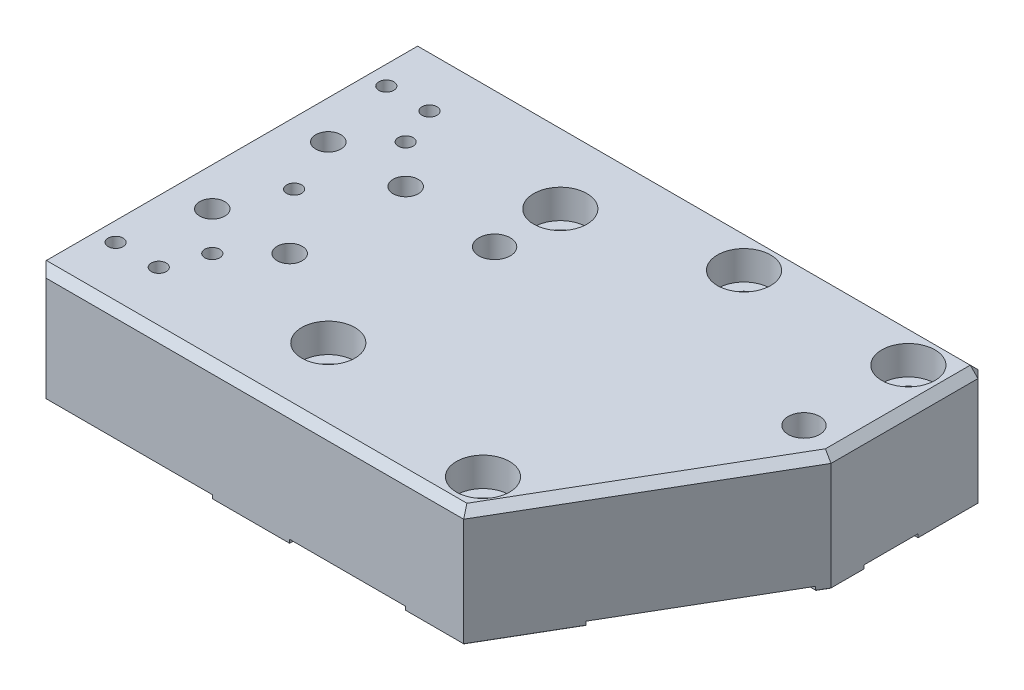
from build123d import *

# Parameters (mm, degrees)
EXTRUDE1_DEPTH                                   = 38.1
SKETCH2_R                                        = 1.59512
PIN_SLOT_HOLES_TO_MAGNET_BLOCK_DEPTH             = 6.35
SKETCH3_W                                        = 19.05
SKETCH3_H                                        = 9.525
SKETCH3_W_2                                      = 7.62
SKETCH3_H_2                                      = 11.43
SKETCH3_H_3                                      = 7.62
EXTRUDE3_DEPTH                                   = 1.27
TAPPED_HOLE_FOR_1_4_20_HELICOIL1_AT_2_COUNT      = 2
TAPPED_HOLE_FOR_1_4_20_HELICOIL1_AT_2_PITCH      = 49.6966108
TAPPED_HOLE_FOR_1_4_20_HELICOIL1_AT_3_COUNT      = 2
TAPPED_HOLE_FOR_1_4_20_HELICOIL1_AT_3_PITCH      = 49.6966108
SKETCH13_R                                       = 3.18389
PIN_SLOT_HOLES_TO_STAGE2_DEPTH                   = 12.7
F_3_8_CLEARANCE_HOLE1_D                          = 10.31748
F_3_8_CLEARANCE_HOLE1_DEPTH                      = 25.4
F_3_8_CLEARANCE_HOLE1_TIP                        = 3.09968371
SKETCH16_R                                       = 1.59512
PIN_SLOT_HOLES_TOOLING_BTACKET_DEPTH             = 6.35
F_8_CLEARANCE_HOLE1_D                            = 4.9149
F_8_CLEARANCE_HOLE1_DEPTH                        = 31.75
F_8_CLEARANCE_HOLE1_TIP                          = 1.476584928
F_8_CLEARANCE_HOLE2_D                            = 4.9149
F_8_CLEARANCE_HOLE2_DEPTH                        = 22.86
F_8_CLEARANCE_HOLE2_TIP                          = 1.476584928
CBORE_FOR_3_8_SOCKET_HEAD_CAP_SCREW1_D           = 10.0838
CBORE_FOR_3_8_SOCKET_HEAD_CAP_SCREW1_CBORE_D     = 17.4625
CBORE_FOR_3_8_SOCKET_HEAD_CAP_SCREW1_CBORE_DEPTH = 9.525
CBORE_FOR_8_SOCKET_HEAD_CAP_SCREW1_D             = 4.9149
CBORE_FOR_8_SOCKET_HEAD_CAP_SCREW1_CBORE_D       = 8.255
CBORE_FOR_8_SOCKET_HEAD_CAP_SCREW1_CBORE_DEPTH   = 5.842
CHAMFER2_SIZE                                    = 2.286
CHAMFER1_SIZE                                    = 2.54
CHAMFER3_SIZE                                    = 0.127
CHAMFER4_SIZE                                    = 0.762


with BuildPart() as part:
    # Sketch1 → Extrude1 (new body)
    with BuildSketch(Plane(origin=(0, 0, 0), x_dir=(1, 0, 0), z_dir=(0, 1, 0))):
        Polygon((69.85, -63.5), (114.3, 12.7), (114.3, 63.5), (-69.85, 63.5), (-69.85, -63.5), align=None)
    extrude(amount=EXTRUDE1_DEPTH)

    # Sketch2 → Pin & Slot holes to Magnet block (cut)
    with BuildSketch(Plane.XZ):
        with Locations(Location((-44.45, 31.75, 0), (0, 0, 270))):
            Circle(SKETCH2_R)
        with BuildLine():
            Line((-42.85488, -30.1625), (-42.85488, -33.3375))
            ThreePointArc((-42.85488, -33.3375), (-44.45, -34.93262), (-46.04512, -33.3375))
            Line((-46.04512, -33.3375), (-46.04512, -30.1625))
            ThreePointArc((-46.04512, -30.1625), (-44.45, -28.56738), (-42.85488, -30.1625))
        make_face()
    extrude(amount=-PIN_SLOT_HOLES_TO_MAGNET_BLOCK_DEPTH, mode=Mode.SUBTRACT)

    # Sketch3 → Extrude3 (cut)
    with BuildSketch(Plane.XZ):
        Polygon((114.3, -23.495), (114.3, -41.275), (91.44, -41.275), (91.44, -63.5), (57.15, -63.5), (57.15, -41.275), (38.1, -41.275), (38.1, -63.5), (12.7, -63.5), (12.7, 63.5), (50.8, 63.5), (50.8, 38.1), (84.666666667, 38.1), (112.447916667, -9.525), (91.44, -9.525), (91.44, -23.495), align=None)
        Polygon((-69.85, -63.5), (-69.85, -23.8125), (-50.8, -23.8125), (-50.8, -14.2875), (-69.85, -14.2875), (-69.85, 14.2875), (-50.8, 14.2875), (-50.8, 23.8125), (-69.85, 23.8125), (-69.85, 63.5), (-12.7, 63.5), (-12.7, -63.5), align=None)
        with Locations((-28.575, -19.05)):
            Rectangle(SKETCH3_W, SKETCH3_H, mode=Mode.SUBTRACT)
        with Locations((-28.575, 19.05)):
            Rectangle(SKETCH3_W, SKETCH3_H, mode=Mode.SUBTRACT)
        with Locations((-44.45, -31.75)):
            Rectangle(SKETCH3_W_2, SKETCH3_H_2, mode=Mode.SUBTRACT)
        with Locations((-44.45, 31.75)):
            Rectangle(SKETCH3_W_2, SKETCH3_H_3, mode=Mode.SUBTRACT)
    extrude(amount=-EXTRUDE3_DEPTH, mode=Mode.SUBTRACT)

    # Sketch8 → Tapped Hole for 1/4-20 Helicoil1 (revolve, cut)
    with BuildSketch(Plane(origin=(-69.85, 30.48, 0), x_dir=(0, 0, 1), z_dir=(0, 1, 0))):
        Polygon((0, 0), (0, 22.553027343), (3.3782, 20.5232), (3.3782, 11.6586), (4.04749, 11.6586), (4.04749, 0.39751), (4.445, 0), align=None)
    tapped_hole_for_1_4_20_helicoil1 = revolve(axis=Axis((-76.2, 30.48, 0), (1, 0, 0)), mode=Mode.SUBTRACT)

    # Tapped Hole for 1/4-20 Helicoil1 at 2: Tapped Hole for 1/4-20 Helicoil1 ×2
    with Locations(*[Vector(0, -0.44721359549995826, 0.8944271909999157) * (i * TAPPED_HOLE_FOR_1_4_20_HELICOIL1_AT_2_PITCH) for i in range(1, TAPPED_HOLE_FOR_1_4_20_HELICOIL1_AT_2_COUNT)]):
        add(tapped_hole_for_1_4_20_helicoil1, mode=Mode.SUBTRACT)

    # Tapped Hole for 1/4-20 Helicoil1 at 3: Tapped Hole for 1/4-20 Helicoil1 ×2
    with Locations(*[Vector(0, -0.44721359549995826, -0.8944271909999157) * (i * TAPPED_HOLE_FOR_1_4_20_HELICOIL1_AT_3_PITCH) for i in range(1, TAPPED_HOLE_FOR_1_4_20_HELICOIL1_AT_3_COUNT)]):
        add(tapped_hole_for_1_4_20_helicoil1, mode=Mode.SUBTRACT)

    # Sketch13 → Pin & Slot holes to Stage2 (cut)
    with BuildSketch(Plane.XZ):
        with Locations(Location((0, -16.51, 0), (0, 0, 270))):
            Circle(SKETCH13_R)
        with BuildLine():
            Line((98.425, -13.32611), (104.775, -13.32611))
            ThreePointArc((104.775, -13.32611), (107.95889, -16.51), (104.775, -19.69389))
            Line((104.775, -19.69389), (98.425, -19.69389))
            ThreePointArc((98.425, -19.69389), (95.24111, -16.51), (98.425, -13.32611))
        make_face()
    extrude(amount=-PIN_SLOT_HOLES_TO_STAGE2_DEPTH, mode=Mode.SUBTRACT)

    # 3/8 Clearance Hole1
    with Locations(Plane(origin=(0, 38.1, 0), x_dir=(-1, 0, 0), z_dir=(0, 1, 0))):
        with Locations((0, -16.51), (-101.6, -16.51)):
            Hole(F_3_8_CLEARANCE_HOLE1_D / 2, depth=F_3_8_CLEARANCE_HOLE1_DEPTH)
            with Locations((0, 0, -(F_3_8_CLEARANCE_HOLE1_DEPTH + F_3_8_CLEARANCE_HOLE1_TIP / 2))):  # 118° drill point
                Cone(0, F_3_8_CLEARANCE_HOLE1_D / 2, F_3_8_CLEARANCE_HOLE1_TIP, mode=Mode.SUBTRACT)

    # Sketch16 → Pin & Slot holes, tooling btacket (cut)
    with BuildSketch(Plane.ZY.offset(69.85)):
        with Locations((44.45, 16.51)):
            Circle(SKETCH16_R)
        with BuildLine():
            Line((-42.8625, 14.91488), (-46.0375, 14.91488))
            ThreePointArc((-46.0375, 14.91488), (-47.63262, 16.51), (-46.0375, 18.10512))
            Line((-46.0375, 18.10512), (-42.8625, 18.10512))
            ThreePointArc((-42.8625, 18.10512), (-41.26738, 16.51), (-42.8625, 14.91488))
        make_face()
    extrude(amount=-PIN_SLOT_HOLES_TOOLING_BTACKET_DEPTH, mode=Mode.SUBTRACT)

    # #8 Clearance Hole1
    with Locations(Plane(origin=(0, 38.1, 0), x_dir=(-1, 0, 0), z_dir=(0, 1, 0))):
        with Locations((44.45, 31.75), (44.45, -31.75), (49.3268, 44.45), (49.3268, -44.45)):
            Hole(F_8_CLEARANCE_HOLE1_D / 2, depth=F_8_CLEARANCE_HOLE1_DEPTH)
            with Locations((0, 0, -(F_8_CLEARANCE_HOLE1_DEPTH + F_8_CLEARANCE_HOLE1_TIP / 2))):  # 118° drill point
                Cone(0, F_8_CLEARANCE_HOLE1_D / 2, F_8_CLEARANCE_HOLE1_TIP, mode=Mode.SUBTRACT)

    # #8 Clearance Hole2
    with Locations(Plane(origin=(0, 38.1, 0), x_dir=(-1, 0, 0), z_dir=(0, 1, 0))):
        with Locations((63.5, -44.45), (63.5, 44.45)):
            Hole(F_8_CLEARANCE_HOLE2_D / 2, depth=F_8_CLEARANCE_HOLE2_DEPTH)
            with Locations((0, 0, -(F_8_CLEARANCE_HOLE2_DEPTH + F_8_CLEARANCE_HOLE2_TIP / 2))):  # 118° drill point
                Cone(0, F_8_CLEARANCE_HOLE2_D / 2, F_8_CLEARANCE_HOLE2_TIP, mode=Mode.SUBTRACT)

    # Sketch19 → #8 Clearance Hole3 (revolve, cut)
    with BuildSketch(Plane(origin=(-49.3268, 38.1, 0), x_dir=(0, 0, 1), z_dir=(1, 0, 0))):
        Polygon((0, 0), (0, 11.636584928), (2.45745, 10.16), (2.45745, 0), align=None)
    revolve(axis=Axis((-49.3268, 44.45, 0), (0, -1, 0)), mode=Mode.SUBTRACT)

    # CBORE for 3/8 Socket Head Cap Screw1 (through all)
    with Locations(Plane(origin=(0, 38.1, 0), x_dir=(-1, 0, 0), z_dir=(0, 1, 0))):
        with Locations((0, 38.1), (0, -38.1), (-63.5, 50.8), (-101.6, -50.8), (-47.625, -50.8)):
            CounterBoreHole(CBORE_FOR_3_8_SOCKET_HEAD_CAP_SCREW1_D / 2, CBORE_FOR_3_8_SOCKET_HEAD_CAP_SCREW1_CBORE_D / 2, CBORE_FOR_3_8_SOCKET_HEAD_CAP_SCREW1_CBORE_DEPTH)

    # CBORE for #8 Socket Head Cap Screw1 (through all)
    with Locations(Plane(origin=(0, 38.1, 0), x_dir=(-1, 0, 0), z_dir=(0, 1, 0))):
        with Locations((57.15, 19.05), (31.75, 19.05), (31.75, -19.05), (57.15, -19.05)):
            CounterBoreHole(CBORE_FOR_8_SOCKET_HEAD_CAP_SCREW1_D / 2, CBORE_FOR_8_SOCKET_HEAD_CAP_SCREW1_CBORE_D / 2, CBORE_FOR_8_SOCKET_HEAD_CAP_SCREW1_CBORE_DEPTH)

    # Chamfer2
    chamfer2_edges = [part.edges().sort_by_distance(p)[0] for p in [
        (0, 0, -13.32611),
        (95.24111, 0, -16.51),
        (101.6, 0, -19.69389),
        (107.95889, 0, -16.51),
        (101.6, 0, -13.32611),
    ]]
    chamfer(chamfer2_edges, length=CHAMFER2_SIZE)

    # Chamfer1
    chamfer1_edges = [part.edges().sort_by_distance(p)[0] for p in [
        (114.3, 38.1, -38.1),
        (22.225, 38.1, -63.5),
        (0, 38.1, 63.5),
        (92.075, 38.1, 25.4),
        (-69.85, 19.685, 63.5),
        (-69.85, 19.685, -63.5),
        (114.3, 19.05, -63.5),
    ]]
    chamfer(chamfer1_edges, length=CHAMFER1_SIZE)

    # Chamfer3
    chamfer3_edges = [part.edges().sort_by_distance(p)[0] for p in [
        (60.325, 0, 63.5),
        (47.625, 0, -63.5),
        (0, 0, -63.5),
        (114.3, 0, -51.1175),
        (113.373958333, 0, -11.1125),
        (38.1, 0, -52.3875),
        (47.625, 0, -41.275),
        (57.15, 0, -52.3875),
        (91.44, 0, -52.3875),
        (102.87, 0, -41.275),
        (102.87, 0, -23.495),
        (91.44, 0, -16.51),
        (101.943958333, 0, -9.525),
        (67.733333333, 0, 38.1),
        (50.8, 0, 50.8),
        (12.7, 0, 0),
        (42.5831, 0, -50.8),
        (0, 0, 63.5),
        (-69.85, 0, -19.05),
        (96.5581, 0, -50.8),
        (-69.85, 0, 19.05),
        (58.4581, 0, 50.8),
        (-5.0419, 0, -38.1),
        (-5.0419, 0, 38.1),
        (-59.60745, 0, -19.05),
        (-34.20745, 0, -19.05),
        (-34.20745, 0, 19.05),
        (-59.60745, 0, 19.05),
        (101.6, 0, -63.5),
        (113.03, 0, -62.23),
        (-69.85, 38.1, 0),
        (114.3, 0, -18.0975),
        (-12.7, 0, 0),
        (-60.325, 0, 23.8125),
        (-50.8, 0, 19.05),
        (-60.325, 0, 14.2875),
        (-60.325, 0, -14.2875),
        (-50.8, 0, -19.05),
        (-60.325, 0, -23.8125),
        (-28.575, 0, -23.8125),
        (77.258333333, 0, 50.8),
        (-38.1, 0, -19.05),
        (-28.575, 0, -14.2875),
        (-19.05, 0, -19.05),
        (-28.575, 0, 14.2875),
        (-38.1, 0, 19.05),
        (-28.575, 0, 23.8125),
        (-19.05, 0, 19.05),
        (-44.45, 0, -37.465),
        (-48.26, 0, -31.75),
        (-44.45, 0, -26.035),
        (-40.64, 0, -31.75),
        (-44.45, 0, 27.94),
        (-48.26, 0, 31.75),
        (-44.45, 0, 35.56),
        (-40.64, 0, 31.75),
    ]]
    chamfer(chamfer3_edges, length=CHAMFER3_SIZE)

    # Chamfer4
    chamfer4_edges = [part.edges().sort_by_distance(p)[0] for p in [
        (-44.45, 0, 33.34512),
        (-44.45, 0, -28.56738),
        (-69.85, 16.51, 42.85488),
        (-46.04512, 0, -31.75),
        (-44.45, 0, -34.93262),
        (-69.85, 16.51, -41.26738),
        (-69.85, 18.10512, -44.45),
        (-69.85, 16.51, -47.63262),
        (-69.85, 14.91488, -44.45),
        (-42.85488, 0, -31.75),
    ]]
    chamfer(chamfer4_edges, length=CHAMFER4_SIZE)


solid = part.part
